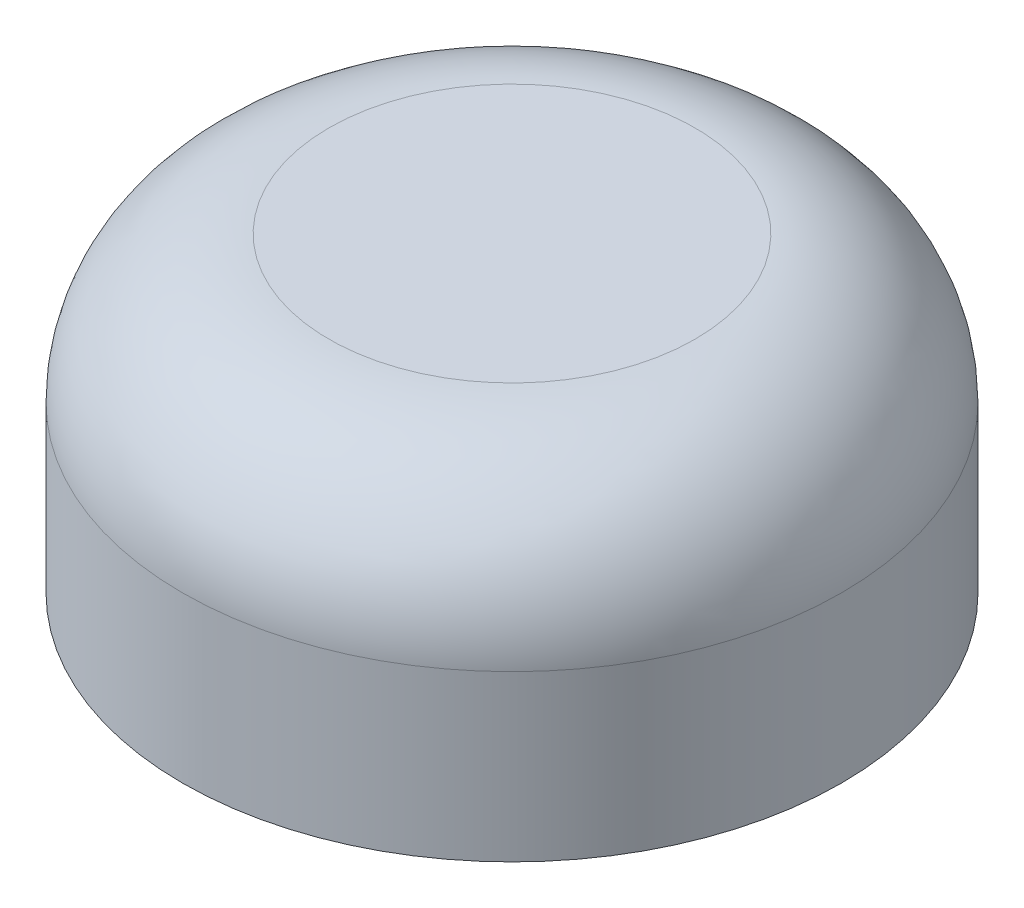
from build123d import *


with BuildPart() as part:
    # Schizzo1 → Rivoluzione1 (revolve)
    with BuildSketch(Plane.XY):
        with BuildLine():
            Line((0, 0), (1.5, 0))
            Line((1.5, 0), (1.5, -2.5))
            Line((1.5, -2.5), (4.5, -2.5))
            Line((4.5, -2.5), (4.5, -0.25))
            ThreePointArc((4.5, -0.25), (3.914213562, 1.164213562), (2.5, 1.75))
            Line((2.5, 1.75), (0, 1.75))
            Line((0, 1.75), (0, 0))
        make_face()
    revolve(axis=Axis((0, 1.75, 0), (0, -1, 0)))


solid = part.part
